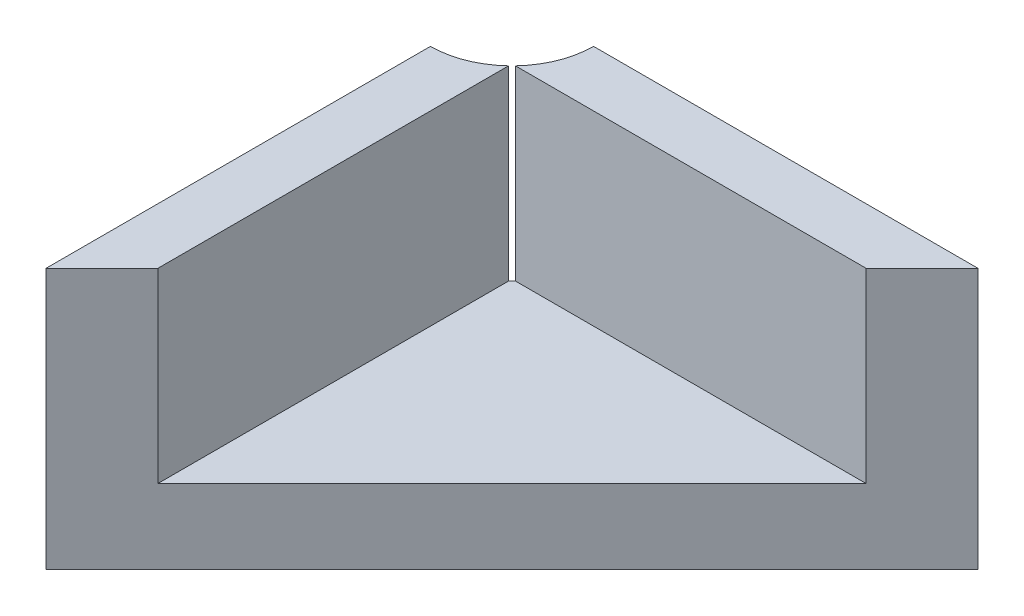
from build123d import *

# Parameters (mm, degrees)
SKETCH2_W           = 10
SKETCH2_H           = 10
BOSS_EXTRUDE1_DEPTH = 1.6
SKETCH4_W           = 10
SKETCH4_H           = 10
SKETCH4_W_2         = 7.6
SKETCH4_H_2         = 7.6
EXTRUDE_THIN1_DEPTH = 4
CUT_EXTRUDE1_DEPTH  = 5.6
SKETCH6_R           = 1.75
CUT_EXTRUDE2_DEPTH  = 5.6


with BuildPart() as part:
    # Sketch2 → Boss-Extrude1 (new body)
    with BuildSketch(Plane(origin=(0, 0, 0), x_dir=(1, 0, 0), z_dir=(0, 1, 0))):
        Rectangle(SKETCH2_W, SKETCH2_H)
    extrude(amount=BOSS_EXTRUDE1_DEPTH)

    # Sketch4 → Extrude-Thin1 (add)
    with BuildSketch(Plane(origin=(0, 1.6, 0), x_dir=(1, 0, 0), z_dir=(0, 1, 0))):
        Rectangle(SKETCH4_W, SKETCH4_H)
        Rectangle(SKETCH4_W_2, SKETCH4_H_2, mode=Mode.SUBTRACT)
    extrude(amount=EXTRUDE_THIN1_DEPTH)

    # Sketch5 → Cut-Extrude1 (cut)
    with BuildSketch(Plane.XZ):
        Polygon((-5, 5), (5, 5), (5, -5), align=None)
    extrude(amount=-CUT_EXTRUDE1_DEPTH, mode=Mode.SUBTRACT)

    # Sketch6 → Cut-Extrude2 (cut)
    with BuildSketch(Plane.XZ):
        with Locations((-5, -5)):
            Circle(SKETCH6_R)
    extrude(amount=-CUT_EXTRUDE2_DEPTH, mode=Mode.SUBTRACT)


solid = part.part
